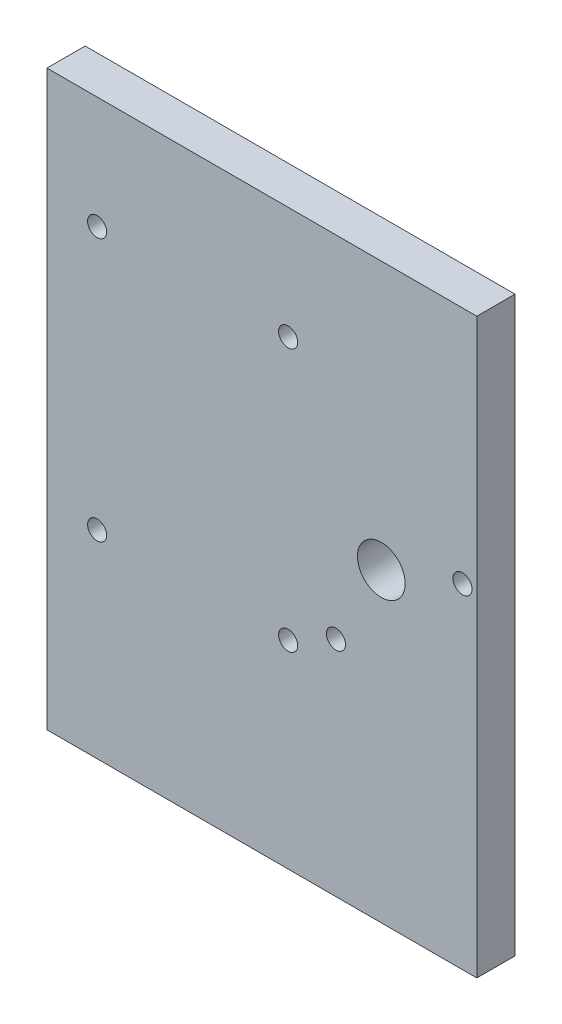
from build123d import *

# Parameters (mm, degrees)
SKETCH1_W           = 90
SKETCH1_H           = 120
BOSS_EXTRUDE1_DEPTH = 8
SKETCH2_R           = 5
CUT_EXTRUDE1_DEPTH  = 9
SKETCH3_R           = 2
CUT_EXTRUDE2_DEPTH  = 9
SKETCH4_R           = 2
CUT_EXTRUDE3_DEPTH  = 9


with BuildPart() as part:
    # Sketch1 → Boss-Extrude1 (new body)
    with BuildSketch(Plane.XY):
        with Locations((45, 60)):
            Rectangle(SKETCH1_W, SKETCH1_H)
    extrude(amount=BOSS_EXTRUDE1_DEPTH)

    # Sketch2 → Cut-Extrude1 (cut, through all)
    with BuildSketch(Plane.XY.offset(8)):
        with Locations((70, 64)):
            Circle(SKETCH2_R)
    extrude(amount=-CUT_EXTRUDE1_DEPTH, mode=Mode.SUBTRACT)

    # Sketch3 → Cut-Extrude2 (cut, through all)
    with BuildSketch(Plane.XY.offset(8)):
        with Locations((87, 70)):
            Circle(SKETCH3_R)
        with Locations((60.5, 46.7)):
            Circle(SKETCH3_R)
    extrude(amount=-CUT_EXTRUDE2_DEPTH, mode=Mode.SUBTRACT)

    # Sketch4 → Cut-Extrude3 (cut, through all)
    with BuildSketch(Plane.XY.offset(8)):
        with Locations((50.5, 96.5)):
            Circle(SKETCH4_R)
        with Locations((10.5, 96.5)):
            Circle(SKETCH4_R)
        with Locations((50.5, 41.5)):
            Circle(SKETCH4_R)
        with Locations((10.5, 41.5)):
            Circle(SKETCH4_R)
    extrude(amount=-CUT_EXTRUDE3_DEPTH, mode=Mode.SUBTRACT)


solid = part.part
